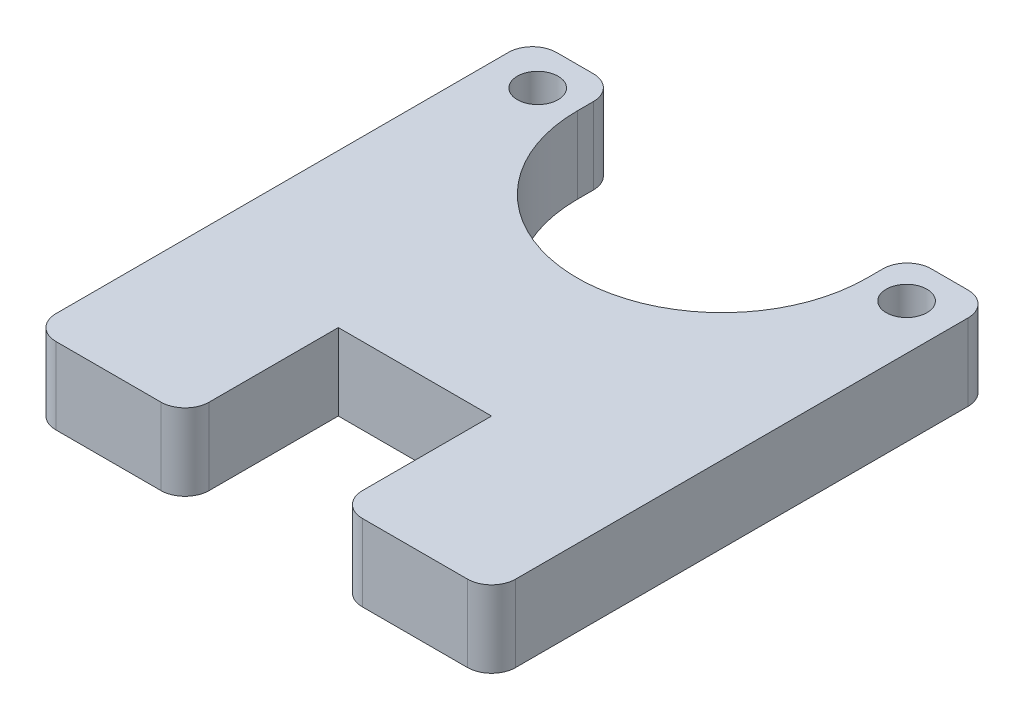
from build123d import *

# Parameters (mm, degrees)
SKETCH1_R        = 0.8449945
SKETCH1_W        = 19.05
SKETCH1_H        = 5.999999938
SKETCH1_W_2      = 6.35
SKETCH1_H_2      = 6.35
MOUNT_BODY_DEPTH = 3.175
FILLET3_R        = 1


with BuildPart() as part:
    # Sketch1 → Mount Body (new body)
    with BuildSketch(Plane(origin=(0, 0, 0), x_dir=(1, 0, 0), z_dir=(0, 1, 0))):
        Polygon((0, 14.393639996), (0, 5.999999938), (3.5249993, 5.999999938), (3.5249993, 12.728644596), (3.5249993, 14.393639996), align=None)
        with Locations((1.88250068, 12.728644596)):
            Circle(SKETCH1_R, mode=Mode.SUBTRACT)
        with BuildLine():
            Line((3.5249993, 12.728644596), (3.5249993, 5.999999938))
            Line((3.5249993, 5.999999938), (15.5250007, 5.999999938))
            Line((15.5250007, 5.999999938), (15.5250007, 12.728637738))
            ThreePointArc((15.5250007, 12.728637738), (9.524996571, 6.728637038), (3.5249993, 12.728644596))
        make_face()
        Polygon((15.5250007, 12.728637738), (15.5250007, 5.999999938), (19.05, 5.999999938), (19.05, 14.393639996), (15.5250007, 14.393639996), align=None)
        with Locations((17.16749932, 12.728637738)):
            Circle(SKETCH1_R, mode=Mode.SUBTRACT)
        with Locations((9.525, 2.999999969)):
            Rectangle(SKETCH1_W, SKETCH1_H)
        with Locations((3.175, -3.175)):
            Rectangle(SKETCH1_W_2, SKETCH1_H_2)
        with Locations((15.875, -3.175)):
            Rectangle(SKETCH1_W_2, SKETCH1_H_2)
    extrude(amount=MOUNT_BODY_DEPTH)

    # Fillet3
    fillet3_edges = [part.edges().sort_by_distance(p)[0] for p in [
        (19.05, 1.5875, 6.35),
        (12.7, 1.5875, 6.35),
        (6.35, 1.5875, 6.35),
        (0, 1.5875, 6.35),
        (0, 1.5875, -14.393639996),
        (3.5249993, 1.5875, -14.393639996),
        (15.5250007, 1.5875, -14.393639996),
        (19.05, 1.5875, -14.393639996),
    ]]
    fillet(fillet3_edges, radius=FILLET3_R)


solid = part.part
